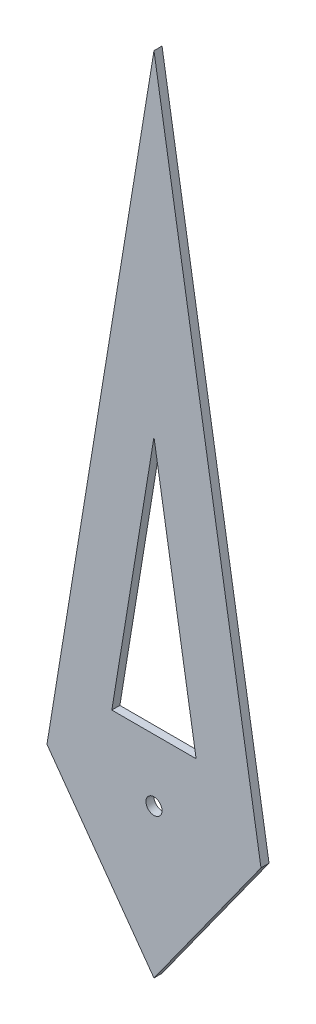
from build123d import *

# Parameters (mm, degrees)
BOSS_EXTRUDE1_DEPTH = 0.05
SKETCH2_R           = 0.05
CUT_EXTRUDE1_DEPTH  = 0.05


with BuildPart() as part:
    # Sketch1 → Boss-Extrude1 (new body)
    with BuildSketch(Plane.XY):
        Polygon((0, 3.67739105), (0.664568148, -0.385728496), (0, -1.310201981), (-0.664568148, -0.385728496), align=None)
        Polygon((-0.261710049, 0), (0.261710049, 0), (0, 1.600075505), align=None, mode=Mode.SUBTRACT)
    extrude(amount=BOSS_EXTRUDE1_DEPTH)

    # Sketch2 → Cut-Extrude1 (cut)
    with BuildSketch(Plane.XY.offset(0.05)):
        with Locations((0, -0.385728496)):
            Circle(SKETCH2_R)
    extrude(amount=-CUT_EXTRUDE1_DEPTH, mode=Mode.SUBTRACT)


solid = part.part
